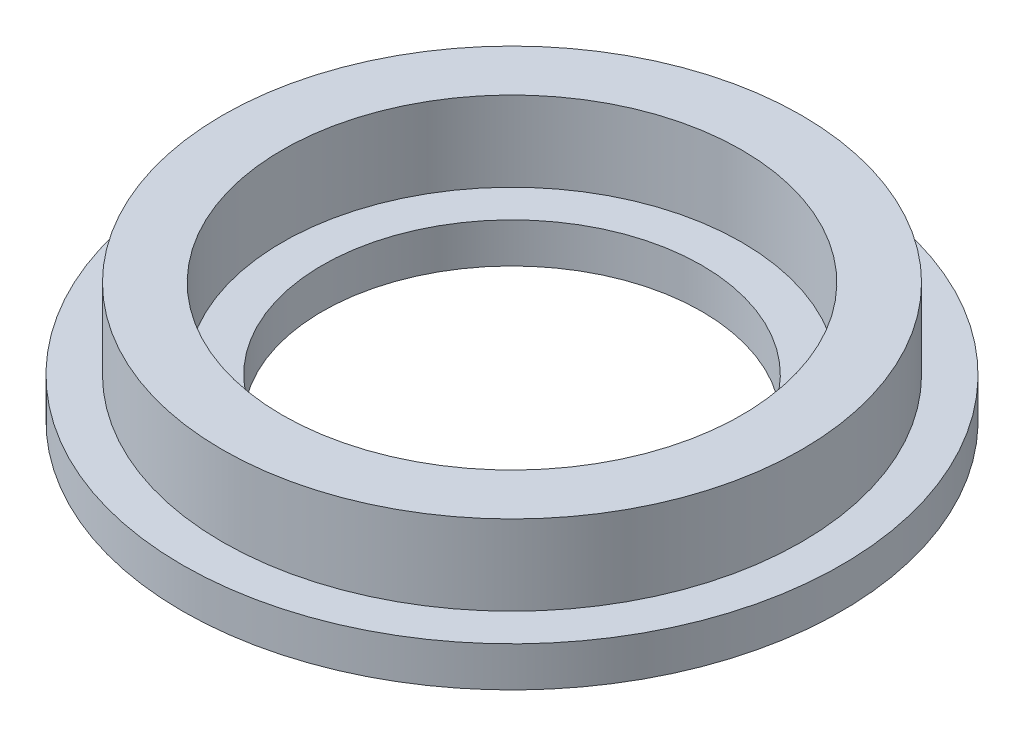
from build123d import *


with BuildPart() as part:
    # Skizze1 → Rotation1 (revolve)
    with BuildSketch(Plane.XY):
        Polygon((-9.5, 0), (-16.5, 0), (-16.5, 2), (-14.5, 2), (-14.5, 6), (-11.5, 6), (-11.5, 2), (-9.5, 2), align=None)
    revolve(axis=Axis((0, 0, 0), (0, 1, 0)))


solid = part.part
